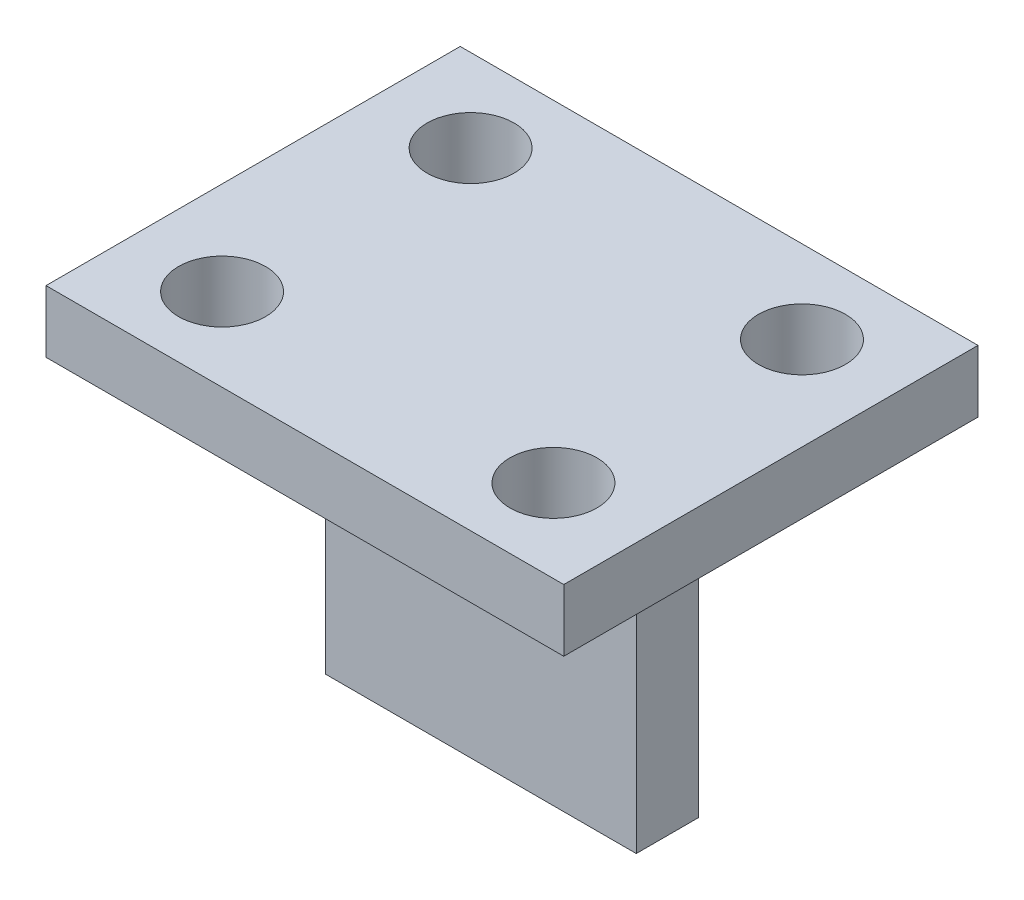
from build123d import *

# Parameters (mm, degrees)
SKETCH1_W                      = 25
SKETCH1_H                      = 20
BOSS_EXTRUDE1_DEPTH            = 1.5
SKETCH2_W                      = 15
SKETCH2_H                      = 3
BOSS_EXTRUDE2_DEPTH            = 15
CUT_EXTRUDE1_REACH             = 20
SKETCH3_R                      = 2.1
CUT_EXTRUDE1_DIRECTION_2_DEPTH = 1


with BuildPart() as part:
    # Sketch1 → Boss-Extrude1 (new body, symmetric)
    with BuildSketch(Plane(origin=(0, 0, 0), x_dir=(1, 0, 0), z_dir=(0, 1, 0))):
        Rectangle(SKETCH1_W, SKETCH1_H)
    extrude(amount=BOSS_EXTRUDE1_DEPTH, both=True)

    # Sketch2 → Boss-Extrude2 (add)
    with BuildSketch(Plane.XZ.offset(1.5)):
        Rectangle(SKETCH2_W, SKETCH2_H)
    extrude(amount=BOSS_EXTRUDE2_DEPTH)

    # Sketch3 → Cut-Extrude1 (cut, up to next)
    with BuildSketch(Plane(origin=(0, 1.5, 0), x_dir=(1, 0, 0), z_dir=(0, 1, 0)), mode=Mode.PRIVATE) as cut_extrude1_sk1:
        with Locations((-8, 6)):
            Circle(SKETCH3_R)
    cut_extrude1_tool1 = extrude(cut_extrude1_sk1.sketch, amount=-CUT_EXTRUDE1_REACH, mode=Mode.PRIVATE) & part.part
    add(cut_extrude1_tool1.solids().sort_by_distance((-8, 1.5, -6))[0], mode=Mode.SUBTRACT)
    # Sketch3 → Cut-Extrude1 (cut, up to next)
    with BuildSketch(Plane(origin=(0, 1.5, 0), x_dir=(1, 0, 0), z_dir=(0, 1, 0)), mode=Mode.PRIVATE) as cut_extrude1_sk2:
        with Locations((8, 6)):
            Circle(SKETCH3_R)
    cut_extrude1_tool2 = extrude(cut_extrude1_sk2.sketch, amount=-CUT_EXTRUDE1_REACH, mode=Mode.PRIVATE) & part.part
    add(cut_extrude1_tool2.solids().sort_by_distance((8, 1.5, -6))[0], mode=Mode.SUBTRACT)
    # Sketch3 → Cut-Extrude1 (cut, up to next)
    with BuildSketch(Plane(origin=(0, 1.5, 0), x_dir=(1, 0, 0), z_dir=(0, 1, 0)), mode=Mode.PRIVATE) as cut_extrude1_sk3:
        with Locations((8, -6)):
            Circle(SKETCH3_R)
    cut_extrude1_tool3 = extrude(cut_extrude1_sk3.sketch, amount=-CUT_EXTRUDE1_REACH, mode=Mode.PRIVATE) & part.part
    add(cut_extrude1_tool3.solids().sort_by_distance((8, 1.5, 6))[0], mode=Mode.SUBTRACT)
    # Sketch3 → Cut-Extrude1 (cut, up to next)
    with BuildSketch(Plane(origin=(0, 1.5, 0), x_dir=(1, 0, 0), z_dir=(0, 1, 0)), mode=Mode.PRIVATE) as cut_extrude1_sk4:
        with Locations((-8, -6)):
            Circle(SKETCH3_R)
    cut_extrude1_tool4 = extrude(cut_extrude1_sk4.sketch, amount=-CUT_EXTRUDE1_REACH, mode=Mode.PRIVATE) & part.part
    add(cut_extrude1_tool4.solids().sort_by_distance((-8, 1.5, 6))[0], mode=Mode.SUBTRACT)

    # Sketch3 → Cut-Extrude1 direction 2 (cut)
    with BuildSketch(Plane(origin=(0, 1.5, 0), x_dir=(1, 0, 0), z_dir=(0, 1, 0))):
        with Locations((-8, 6)):
            Circle(SKETCH3_R)
        with Locations((8, 6)):
            Circle(SKETCH3_R)
        with Locations((8, -6)):
            Circle(SKETCH3_R)
        with Locations((-8, -6)):
            Circle(SKETCH3_R)
    extrude(amount=CUT_EXTRUDE1_DIRECTION_2_DEPTH, mode=Mode.SUBTRACT)


solid = part.part
